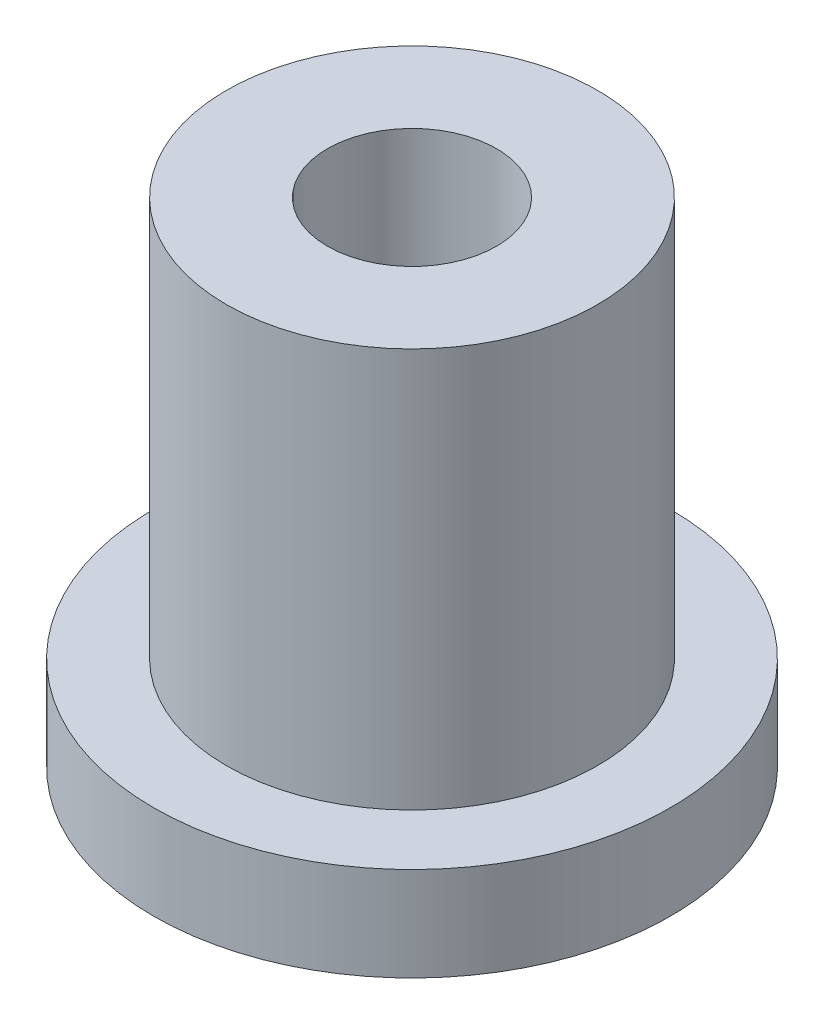
from build123d import *

# Parameters (mm, degrees)
SKETCH1_R           = 5.5
SKETCH1_R_2         = 1.8
BOSS_EXTRUDE1_DEPTH = 2
SKETCH2_R           = 3.95
SKETCH2_R_2         = 1.8
BOSS_EXTRUDE2_DEPTH = 8.5


with BuildPart() as part:
    # Sketch1 → Boss-Extrude1 (new body)
    with BuildSketch(Plane(origin=(0, 0, 0), x_dir=(1, 0, 0), z_dir=(0, 1, 0))):
        with Locations(Location((0, 0, 0), (0, 0, 270))):  # turned: the seam where the file's is
            Circle(SKETCH1_R)
        with Locations(Location((0, 0, 0), (0, 0, 270))):  # turned: the seam where the file's is
            Circle(SKETCH1_R_2, mode=Mode.SUBTRACT)
    extrude(amount=BOSS_EXTRUDE1_DEPTH)

    # Sketch2 → Boss-Extrude2 (add)
    with BuildSketch(Plane(origin=(0, 2, 0), x_dir=(1, 0, 0), z_dir=(0, 1, 0))):
        with Locations(Location((0, 0, 0), (0, 0, 270))):  # turned: the seam where the file's is
            Circle(SKETCH2_R)
        with Locations(Location((0, 0, 0), (0, 0, 270))):  # turned: the seam where the file's is
            Circle(SKETCH2_R_2, mode=Mode.SUBTRACT)
    extrude(amount=BOSS_EXTRUDE2_DEPTH)


solid = part.part
